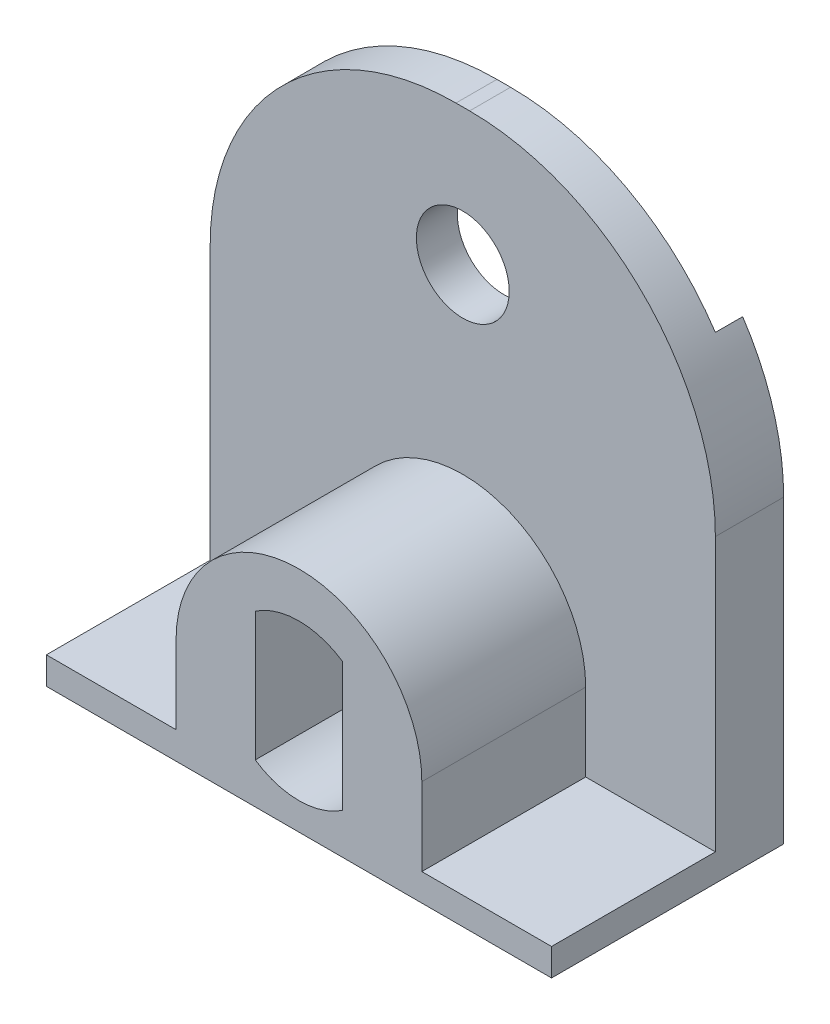
from build123d import *

# Parameters (mm, degrees)
EXTRUDE_1_DEPTH     = 20
FILLET_1_R          = 9
SKETCH_2_R          = 1.7
CUT_EXTRUDE_1_DEPTH = 3.5
SKETCH_3_W          = 18.5
SKETCH_3_H          = 1
EXTRUDE_2_DEPTH     = 6
EXTRUDE_3_DEPTH     = 6


with BuildPart() as part:
    # Эскиз1 → Бобышка-Вытянуть1 (new body)
    with BuildSketch(Plane(origin=(0, 0, 0), x_dir=(1, 0, 0), z_dir=(0, 1, 0))):
        Polygon((0, 0), (15.5, 0), (15.5, 1), (17, 1), (17, -1.5), (-1.5, -1.5), (-1.5, 1), (0, 1), align=None)
    extrude(amount=EXTRUDE_1_DEPTH)

    # Скругление1
    fillet_1_edges = [part.edges().sort_by_distance(p)[0] for p in [
        (-1.5, 20, 0.25),
        (17, 20, 0.25),
    ]]
    fillet(fillet_1_edges, radius=FILLET_1_R)

    # Эскиз2 → Вырез-Вытянуть1 (cut, through all)
    with BuildSketch(Plane.XY.offset(1.5)):
        with Locations((7.75, 15)):
            Circle(SKETCH_2_R)
    extrude(amount=-CUT_EXTRUDE_1_DEPTH, mode=Mode.SUBTRACT)

    # Эскиз3 → Бобышка-Вытянуть2 (add)
    with BuildSketch(Plane.XY.offset(1.5)):
        with Locations((7.75, 0.5)):
            Rectangle(SKETCH_3_W, SKETCH_3_H)
    extrude(amount=EXTRUDE_2_DEPTH)

    # Эскиз4 → Бобышка-Вытянуть3 (add)
    with BuildSketch(Plane.XY.offset(1.5)):
        with BuildLine():
            Line((3.25, 3.85), (3.25, 1.023796375))
            Line((3.25, 1.023796375), (3.25, 0.775352043))
            Line((3.25, 0.775352043), (12.25, 0.775352043))
            Line((12.25, 0.775352043), (12.25, 1.023796375))
            Line((12.25, 1.023796375), (12.25, 3.85))
            ThreePointArc((12.25, 3.85), (7.75, 8.35), (3.25, 3.85))
        make_face()
        with BuildLine():
            Line((6.15, 6.208495283), (6.15, 1.491504717))
            ThreePointArc((6.15, 1.491504717), (7.75, 1), (9.35, 1.491504717))
            Line((9.35, 1.491504717), (9.35, 6.208495283))
            ThreePointArc((9.35, 6.208495283), (7.75, 6.7), (6.15, 6.208495283))
        make_face(mode=Mode.SUBTRACT)
    extrude(amount=EXTRUDE_3_DEPTH)


solid = part.part
